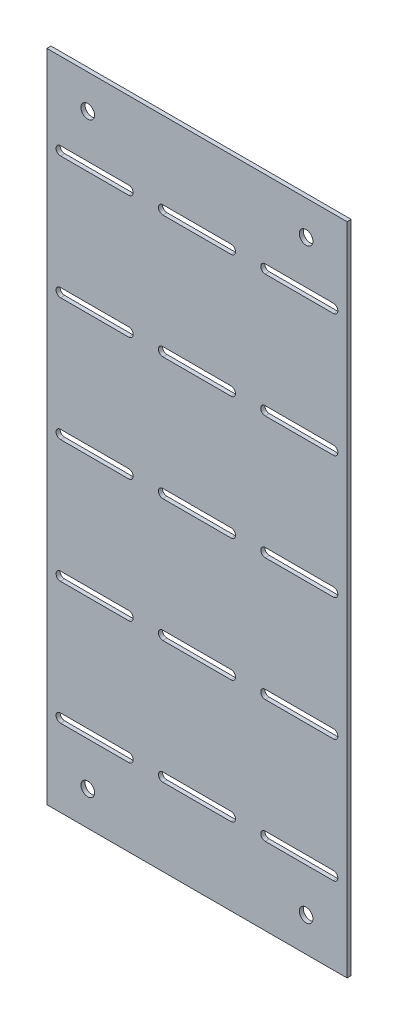
from build123d import *

# Parameters (mm, degrees)
CROQUIS1_W              = 220
CROQUIS1_H              = 480
SALIENTE_EXTRUIR1_DEPTH = 3
CROQUIS2_R              = 5
CORTAR_EXTRUIR1_DEPTH   = 3


with BuildPart() as part:
    # Croquis1 → Saliente-Extruir1 (new body)
    with BuildSketch(Plane.XY):
        Rectangle(CROQUIS1_W, CROQUIS1_H)
    extrude(amount=SALIENTE_EXTRUIR1_DEPTH)

    # Croquis2 → Cortar-Extruir1 (cut)
    with BuildSketch(Plane(origin=(0, 0, 0), x_dir=(-1, 0, 0), z_dir=(0, 0, -1))):
        with Locations((-80, 215)):
            Circle(CROQUIS2_R)
        with Locations((80, 215)):
            Circle(CROQUIS2_R)
        with Locations((80, -215)):
            Circle(CROQUIS2_R)
        with Locations((-80, -215)):
            Circle(CROQUIS2_R)
        with BuildLine():
            Line((-100, 3.25), (-50, 3.25))
            ThreePointArc((-50, 3.25), (-46.75, 0), (-50, -3.25))
            Line((-50, -3.25), (-100, -3.25))
            ThreePointArc((-100, -3.25), (-103.25, 0), (-100, 3.25))
        make_face()
        with BuildLine():
            Line((-100, 93.25), (-50, 93.25))
            ThreePointArc((-50, 93.25), (-46.75, 90), (-50, 86.75))
            Line((-50, 86.75), (-100, 86.75))
            ThreePointArc((-100, 86.75), (-103.25, 90), (-100, 93.25))
        make_face()
        with BuildLine():
            Line((-100, -93.25), (-50, -93.25))
            ThreePointArc((-50, -93.25), (-46.75, -90), (-50, -86.75))
            Line((-50, -86.75), (-100, -86.75))
            ThreePointArc((-100, -86.75), (-103.25, -90), (-100, -93.25))
        make_face()
        with BuildLine():
            Line((-25, 3.25), (25, 3.25))
            ThreePointArc((25, 3.25), (28.25, 0), (25, -3.25))
            Line((25, -3.25), (-25, -3.25))
            ThreePointArc((-25, -3.25), (-28.25, 0), (-25, 3.25))
        make_face()
        with BuildLine():
            Line((-25, 93.25), (25, 93.25))
            ThreePointArc((25, 93.25), (28.25, 90), (25, 86.75))
            Line((25, 86.75), (-25, 86.75))
            ThreePointArc((-25, 86.75), (-28.25, 90), (-25, 93.25))
        make_face()
        with BuildLine():
            Line((-25, -93.25), (25, -93.25))
            ThreePointArc((25, -93.25), (28.25, -90), (25, -86.75))
            Line((25, -86.75), (-25, -86.75))
            ThreePointArc((-25, -86.75), (-28.25, -90), (-25, -93.25))
        make_face()
        with BuildLine():
            Line((50, 3.25), (100, 3.25))
            ThreePointArc((100, 3.25), (103.25, 0), (100, -3.25))
            Line((100, -3.25), (50, -3.25))
            ThreePointArc((50, -3.25), (46.75, 0), (50, 3.25))
        make_face()
        with BuildLine():
            Line((50, 93.25), (100, 93.25))
            ThreePointArc((100, 93.25), (103.25, 90), (100, 86.75))
            Line((100, 86.75), (50, 86.75))
            ThreePointArc((50, 86.75), (46.75, 90), (50, 93.25))
        make_face()
        with BuildLine():
            Line((50, -93.25), (100, -93.25))
            ThreePointArc((100, -93.25), (103.25, -90), (100, -86.75))
            Line((100, -86.75), (50, -86.75))
            ThreePointArc((50, -86.75), (46.75, -90), (50, -93.25))
        make_face()
        with BuildLine():
            Line((-100, 183.25), (-50, 183.25))
            ThreePointArc((-50, 183.25), (-46.75, 180), (-50, 176.75))
            Line((-50, 176.75), (-100, 176.75))
            ThreePointArc((-100, 176.75), (-103.25, 180), (-100, 183.25))
        make_face()
        with BuildLine():
            Line((-25, 183.25), (25, 183.25))
            ThreePointArc((25, 183.25), (28.25, 180), (25, 176.75))
            Line((25, 176.75), (-25, 176.75))
            ThreePointArc((-25, 176.75), (-28.25, 180), (-25, 183.25))
        make_face()
        with BuildLine():
            Line((50, 183.25), (100, 183.25))
            ThreePointArc((100, 183.25), (103.25, 180), (100, 176.75))
            Line((100, 176.75), (50, 176.75))
            ThreePointArc((50, 176.75), (46.75, 180), (50, 183.25))
        make_face()
        with BuildLine():
            Line((-100, -183.25), (-50, -183.25))
            ThreePointArc((-50, -183.25), (-46.75, -180), (-50, -176.75))
            Line((-50, -176.75), (-100, -176.75))
            ThreePointArc((-100, -176.75), (-103.25, -180), (-100, -183.25))
        make_face()
        with BuildLine():
            Line((-25, -183.25), (25, -183.25))
            ThreePointArc((25, -183.25), (28.25, -180), (25, -176.75))
            Line((25, -176.75), (-25, -176.75))
            ThreePointArc((-25, -176.75), (-28.25, -180), (-25, -183.25))
        make_face()
        with BuildLine():
            Line((50, -183.25), (100, -183.25))
            ThreePointArc((100, -183.25), (103.25, -180), (100, -176.75))
            Line((100, -176.75), (50, -176.75))
            ThreePointArc((50, -176.75), (46.75, -180), (50, -183.25))
        make_face()
    extrude(amount=-CORTAR_EXTRUIR1_DEPTH, mode=Mode.SUBTRACT)


solid = part.part
